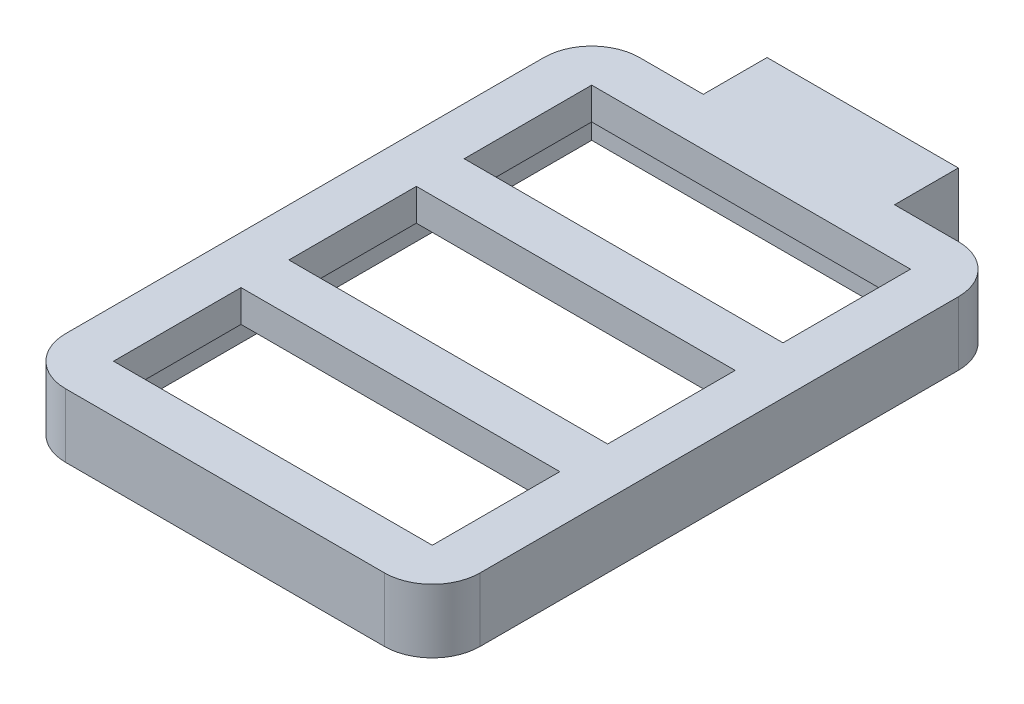
from build123d import *

# Parameters (mm, degrees)
EXTRUDE_1_DEPTH     = 20
SKETCH_2_W          = 100
SKETCH_2_H          = 40
CUT_EXTRUDE_1_DEPTH = 20
FILLET_1_R          = 15
SKETCH_3_W          = 110
SKETCH_3_H          = 160
CUT_EXTRUDE_2_DEPTH = 10


with BuildPart() as part:
    # 스케치1 → 보스-돌출1 (new body)
    with BuildSketch(Plane(origin=(0, 0, 0), x_dir=(1, 0, 0), z_dir=(0, 1, 0))):
        Polygon((-65, 90), (-65, -90), (65, -90), (65, 90), (30, 90), (30, 110), (-30, 110), (-30, 90), align=None)
    extrude(amount=EXTRUDE_1_DEPTH)

    # 스케치2 → 컷-돌출1 (cut)
    with BuildSketch(Plane(origin=(0, 20, 0), x_dir=(1, 0, 0), z_dir=(0, 1, 0))):
        with Locations((0, -55)):
            Rectangle(SKETCH_2_W, SKETCH_2_H)
        with Locations((0, 55)):
            Rectangle(SKETCH_2_W, SKETCH_2_H)
        Rectangle(SKETCH_2_W, SKETCH_2_H)
    extrude(amount=-CUT_EXTRUDE_1_DEPTH, mode=Mode.SUBTRACT)

    # 필렛1
    fillet_1_edges = [part.edges().sort_by_distance(p)[0] for p in [
        (65, 10, -90),
        (65, 10, 90),
        (-65, 10, 90),
        (-65, 10, -90),
    ]]
    fillet(fillet_1_edges, radius=FILLET_1_R)

    # 스케치3 → 컷-돌출2 (cut)
    with BuildSketch(Plane.XZ):
        Rectangle(SKETCH_3_W, SKETCH_3_H)
    extrude(amount=-CUT_EXTRUDE_2_DEPTH, mode=Mode.SUBTRACT)


solid = part.part
